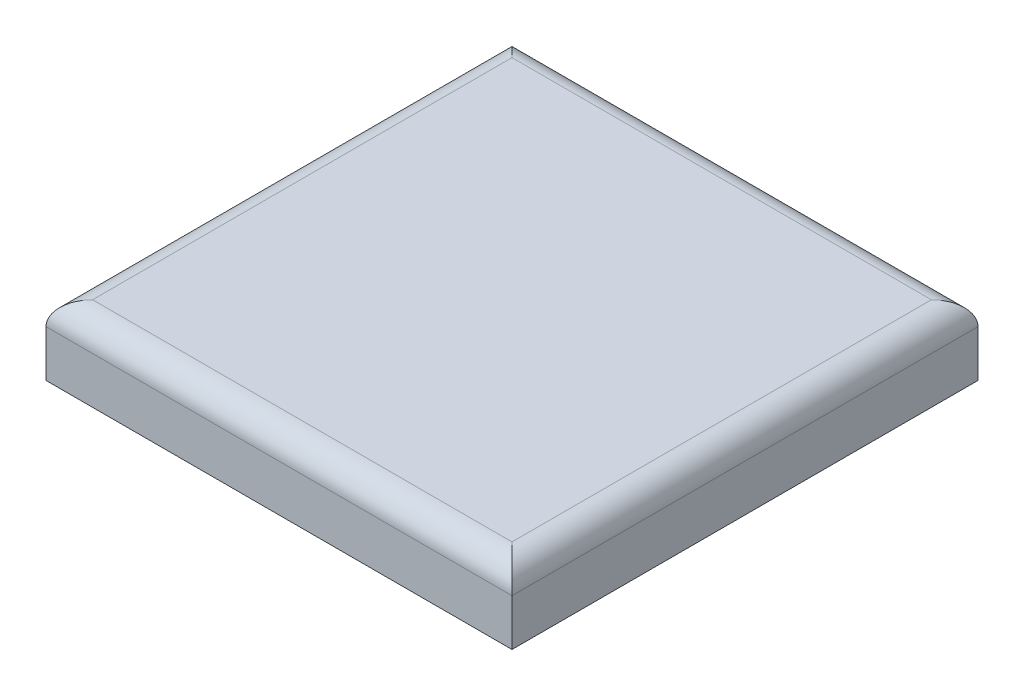
from build123d import *

# Parameters (mm, degrees)
SKETCH1_W           = 20
SKETCH1_H           = 20
BOSS_EXTRUDE1_DEPTH = 3
FILLET1_R           = 1
SKETCH2_R           = 2.5
BOSS_EXTRUDE2_DEPTH = 5


with BuildPart() as part:
    # Sketch1 → Boss-Extrude1 (new body)
    with BuildSketch(Plane(origin=(0, 0, 0), x_dir=(1, 0, 0), z_dir=(0, 1, 0))):
        Rectangle(SKETCH1_W, SKETCH1_H)
    extrude(amount=BOSS_EXTRUDE1_DEPTH)

    # Fillet1
    fillet1_edges = [part.edges().sort_by_distance(p)[0] for p in [
        (-10, 3, 0),
        (0, 3, 10),
        (10, 3, 0),
        (0, 3, -10),
    ]]
    fillet(fillet1_edges, radius=FILLET1_R)

    # Sketch2 → Boss-Extrude2 (add)
    with BuildSketch(Plane.XZ):
        Circle(SKETCH2_R)
    extrude(amount=BOSS_EXTRUDE2_DEPTH)


solid = part.part
